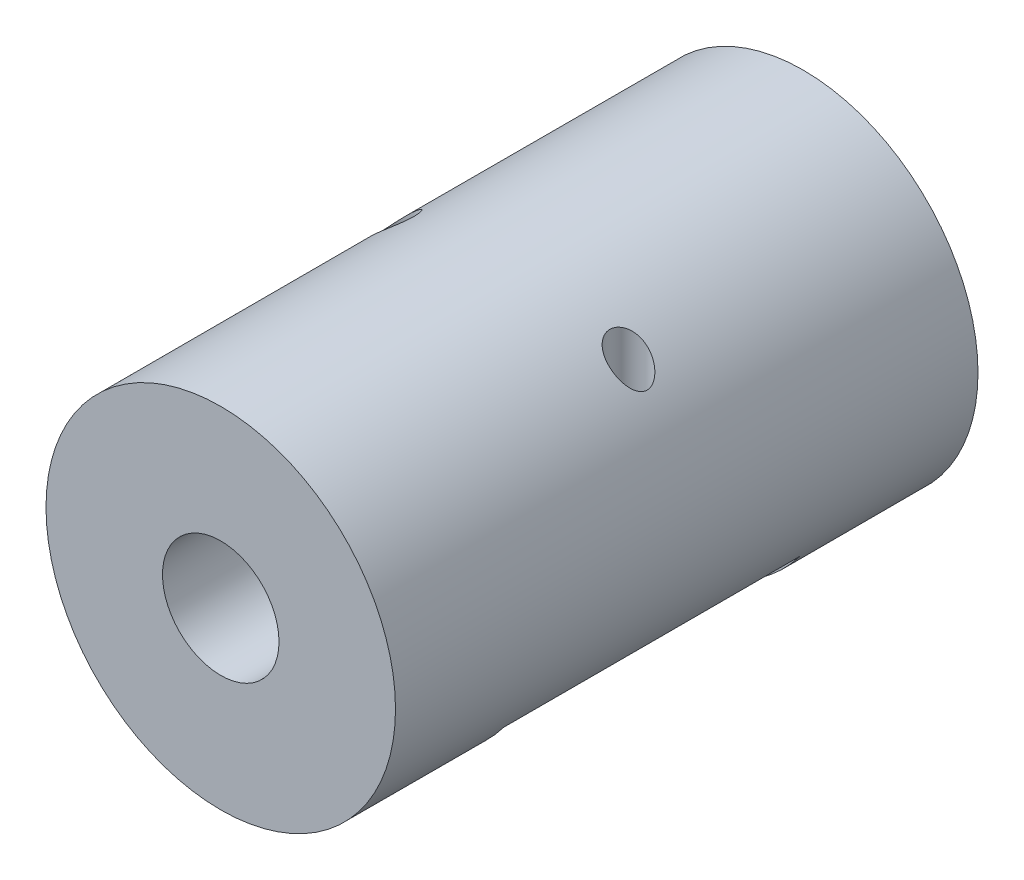
from build123d import *

# Parameters (mm, degrees)
SKETCH1_W               = 10
SKETCH1_H               = 50
CUT_EXTRUDE1_DEPTH      = 12.7
CUT_EXTRUDE1_DEPTH_BACK = 12.7
SKETCH2_W               = 30
SKETCH2_H               = 6
SKETCH3_W               = 1.6
SKETCH3_H               = 21.427389106
SKETCH3_3_W             = 1.6
SKETCH3_3_H             = 21.427389106


with BuildPart() as part:
    # Sketch1 → Revolve1 (revolve)
    with BuildSketch(Plane(origin=(0, 0, 0), x_dir=(1, 0, 0), z_dir=(0, 1, 0))):
        with Locations((10, 0)):
            Rectangle(SKETCH1_W, SKETCH1_H)
    revolve(axis=Axis((0, 0, 25), (0, 0, -1)))

    # Sketch2 → Cut-Extrude1 (cut, two sides: drawn at the far end of the back side and taken through both)
    with BuildSketch(Plane.XY.offset(-CUT_EXTRUDE1_DEPTH_BACK)):
        with Locations((0, -12)):
            Rectangle(SKETCH2_W, SKETCH2_H)
    extrude(amount=CUT_EXTRUDE1_DEPTH + CUT_EXTRUDE1_DEPTH_BACK, mode=Mode.SUBTRACT)

    # Sketch3 → Cut-Revolve1 (revolve, cut)
    with BuildSketch(Plane.XY):
        with Locations((9.2, 1.713694553)):
            Rectangle(SKETCH3_W, SKETCH3_H)
    revolve(axis=Axis((10, -9, 0), (0, -1, 0)), mode=Mode.SUBTRACT)

    # Sketch3_3 → Cut-Revolve2 (revolve, cut)
    with BuildSketch(Plane.XY):
        with Locations((-9.2, 1.713694553)):
            Rectangle(SKETCH3_3_W, SKETCH3_3_H)
    revolve(axis=Axis((-10, -9, 0), (0, -1, 0)), mode=Mode.SUBTRACT)


solid = part.part
